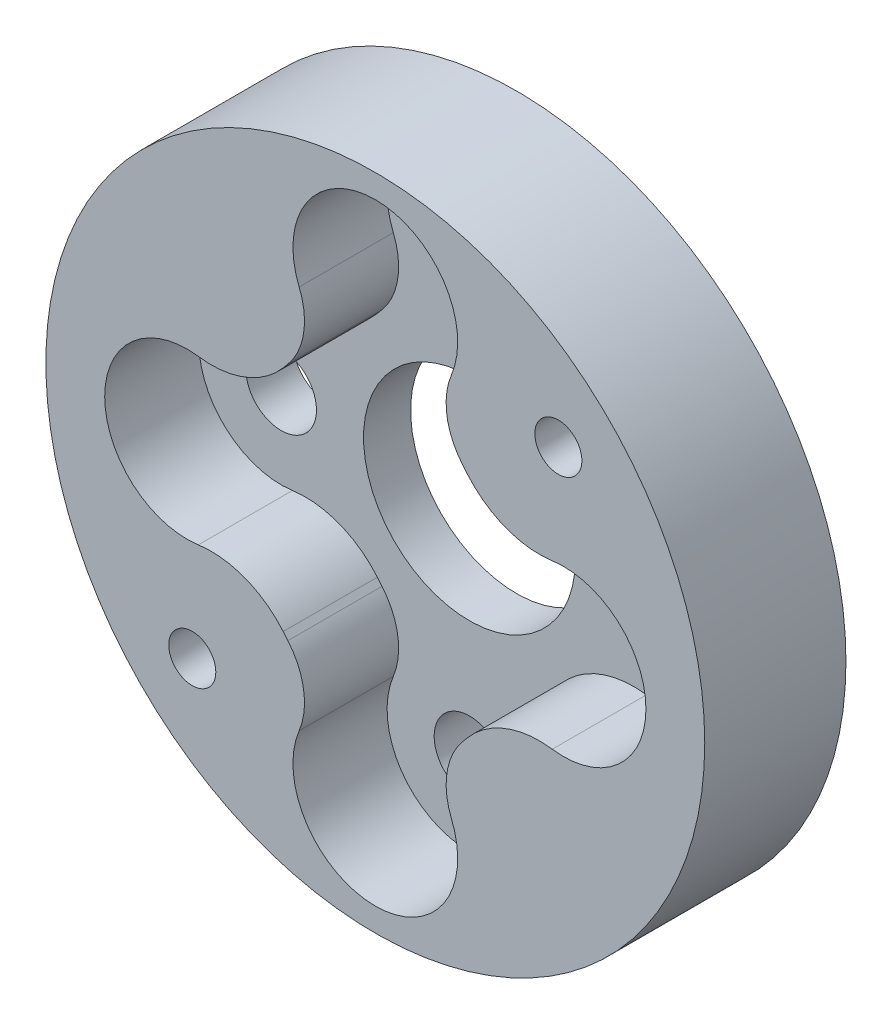
from build123d import *

# Parameters (mm, degrees)
SKETCH_1_R          = 14
EXTRUDE_1_DEPTH     = 2
SKETCH_2_R          = 1.5
SKETCH_2_R_2        = 4.5
CUT_EXTRUDE_1_DEPTH = 3
SKETCH_3_R          = 14
SKETCH_3_R_2        = 1
EXTRUDE_3_DEPTH     = 4
SKETCH_4_R          = 1
CUT_EXTRUDE_2_DEPTH = 7


with BuildPart() as part:
    # 草图1 → 凸台-拉伸1 (new body)
    with BuildSketch(Plane.XY):
        Circle(SKETCH_1_R)
    extrude(amount=EXTRUDE_1_DEPTH)

    # 草图2 → 切除-拉伸1 (cut, through all)
    with BuildSketch(Plane.XY.offset(2)):
        with Locations((-8, 0)):
            Circle(SKETCH_2_R)
        with Locations((0, 9.5)):
            Circle(SKETCH_2_R)
        with Locations((8, 0)):
            Circle(SKETCH_2_R)
        with Locations((0, -9.5)):
            Circle(SKETCH_2_R)
        Circle(SKETCH_2_R_2)
    extrude(amount=-CUT_EXTRUDE_1_DEPTH, mode=Mode.SUBTRACT)

    # 草图3 → 凸台-拉伸3 (add)
    with BuildSketch(Plane.XY.offset(2)):
        Circle(SKETCH_3_R)
        with Locations((-7.778174593, -7.778174593)):
            Circle(SKETCH_3_R_2, mode=Mode.SUBTRACT)
        with Locations((7.778174593, 7.778174593)):
            Circle(SKETCH_3_R_2, mode=Mode.SUBTRACT)
        with BuildLine():
            Line((-3.913416822, -4.852817524), (-3.714267904, -5.089306864))
            ThreePointArc((-3.714267904, -5.089306864), (-3.044670654, -6.56047377), (-3.235616191, -8.165538362))
            ThreePointArc((-3.235616191, -8.165538362), (0, -13), (3.235616191, -8.165538362))
            ThreePointArc((3.235616191, -8.165538362), (3.044670654, -6.56047377), (3.714267904, -5.089306864))
            Line((3.714267904, -5.089306864), (3.913416822, -4.852817524))
            ThreePointArc((3.913416822, -4.852817524), (5.538640325, -3.695403416), (7.520762087, -3.467034904))
            ThreePointArc((7.520762087, -3.467034904), (11.5, 0), (7.520762087, 3.467034904))
            ThreePointArc((7.520762087, 3.467034904), (5.538640325, 3.695403416), (3.913416822, 4.852817524))
            Line((3.913416822, 4.852817524), (3.714267904, 5.089306864))
            ThreePointArc((3.714267904, 5.089306864), (3.044670654, 6.56047377), (3.235616191, 8.165538362))
            ThreePointArc((3.235616191, 8.165538362), (0, 13), (-3.235616191, 8.165538362))
            ThreePointArc((-3.235616191, 8.165538362), (-3.044670654, 6.56047377), (-3.714267904, 5.089306864))
            Line((-3.714267904, 5.089306864), (-3.913416822, 4.852817524))
            ThreePointArc((-3.913416822, 4.852817524), (-5.538640325, 3.695403416), (-7.520762087, 3.467034904))
            ThreePointArc((-7.520762087, 3.467034904), (-11.5, 0), (-7.520762087, -3.467034904))
            ThreePointArc((-7.520762087, -3.467034904), (-5.538640325, -3.695403416), (-3.913416822, -4.852817524))
        make_face(mode=Mode.SUBTRACT)
    extrude(amount=EXTRUDE_3_DEPTH)

    # 草图4 → 切除-拉伸2 (cut, through all)
    with BuildSketch(Plane.XY.offset(6)):
        with Locations((7.778174593, 7.778174593)):
            Circle(SKETCH_4_R)
        with Locations((-7.778174593, -7.778174593)):
            Circle(SKETCH_4_R)
    extrude(amount=-CUT_EXTRUDE_2_DEPTH, mode=Mode.SUBTRACT)


solid = part.part
